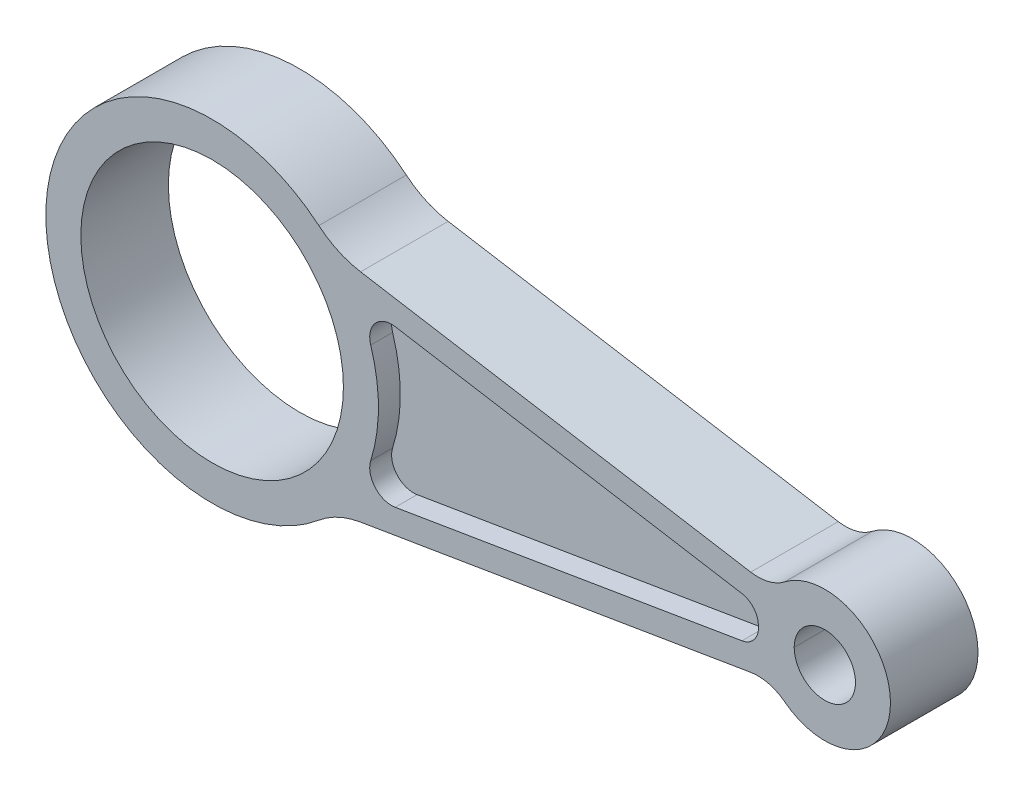
from build123d import *

# Parameters (mm, degrees)
SKETCH1_R          = 30
SKETCH1_R_2        = 7
BASE_EXTRUDE_DEPTH = 20
FILLET1_R          = 10
FILLET2_R          = 20
CUT_EXTRUDE1_DEPTH = 5
CUT_EXTRUDE2_DEPTH = 5


with BuildPart() as part:
    # Sketch1 → Base-Extrude (new body)
    with BuildSketch(Plane.XY):
        with BuildLine():
            Line((27.935473676, 25.760615491), (128.063755469, 9.084385863))
            ThreePointArc((128.063755469, 9.084385863), (155, 0), (128.063755469, -9.084385863))
            Line((128.063755469, -9.084385863), (27.935473676, -25.760615491))
            ThreePointArc((27.935473676, -25.760615491), (-38, 0), (27.935473676, 25.760615491))
        make_face()
        Circle(SKETCH1_R, mode=Mode.SUBTRACT)
        with Locations((140, 0)):
            Circle(SKETCH1_R_2, mode=Mode.SUBTRACT)
    extrude(amount=-BASE_EXTRUDE_DEPTH)

    # Fillet1
    fillet1_edges = [part.edges().sort_by_distance(p)[0] for p in [
        (128.063755469, 9.084385863, -10),
        (128.063755469, -9.084385863, -10),
    ]]
    fillet(fillet1_edges, radius=FILLET1_R)

    # Fillet2
    fillet2_edges = [part.edges().sort_by_distance(p)[0] for p in [
        (27.935473676, 25.760615491, -10),
        (27.935473676, -25.760615491, -10),
    ]]
    fillet(fillet2_edges, radius=FILLET2_R)

    # Sketch2 → Cut-Extrude1 (cut)
    with BuildSketch(Plane.XY):
        with BuildLine():
            Line((41.828554558, 17.870982725), (121.046940728, 4.677267873))
            ThreePointArc((121.046940728, 4.677267873), (123.741079282, 3.147292859), (124.807655013, 0.238406077))
            ThreePointArc((124.807655013, 0.238406077), (123.914202634, -2.958553332), (121.071833732, -4.673121977))
            Line((121.071833732, -4.673121977), (41.828554558, -17.870982725))
            ThreePointArc((41.828554558, -17.870982725), (37.231968897, -16.217361812), (36.238855523, -11.43439331))
            ThreePointArc((36.238855523, -11.43439331), (38, 0), (36.238855523, 11.43439331))
            ThreePointArc((36.238855523, 11.43439331), (37.231968897, 16.217361812), (41.828554558, 17.870982725))
        make_face()
    extrude(amount=-CUT_EXTRUDE1_DEPTH, mode=Mode.SUBTRACT)

    # Sketch3 → Cut-Extrude2 (cut)
    with BuildSketch(Plane(origin=(0, 0, -20), x_dir=(-1, 0, 0), z_dir=(0, 0, -1))):
        with BuildLine():
            Line((-121.445609231, 4.610870174), (-41.828554558, 17.870982725))
            ThreePointArc((-41.828554558, 17.870982725), (-37.231968897, 16.217361812), (-36.238855523, 11.43439331))
            ThreePointArc((-36.238855523, 11.43439331), (-38, 0), (-36.238855523, -11.43439331))
            ThreePointArc((-36.238855523, -11.43439331), (-37.231968897, -16.217361812), (-41.828554558, -17.870982725))
            Line((-41.828554558, -17.870982725), (-121.433526351, -4.612882562))
            ThreePointArc((-121.433526351, -4.612882562), (-124.132861899, -3.076762276), (-125.194211834, -0.157924451))
            ThreePointArc((-125.194211834, -0.157924451), (-124.244145959, 2.952985869), (-121.445609231, 4.610870174))
        make_face()
    extrude(amount=-CUT_EXTRUDE2_DEPTH, mode=Mode.SUBTRACT)


solid = part.part
